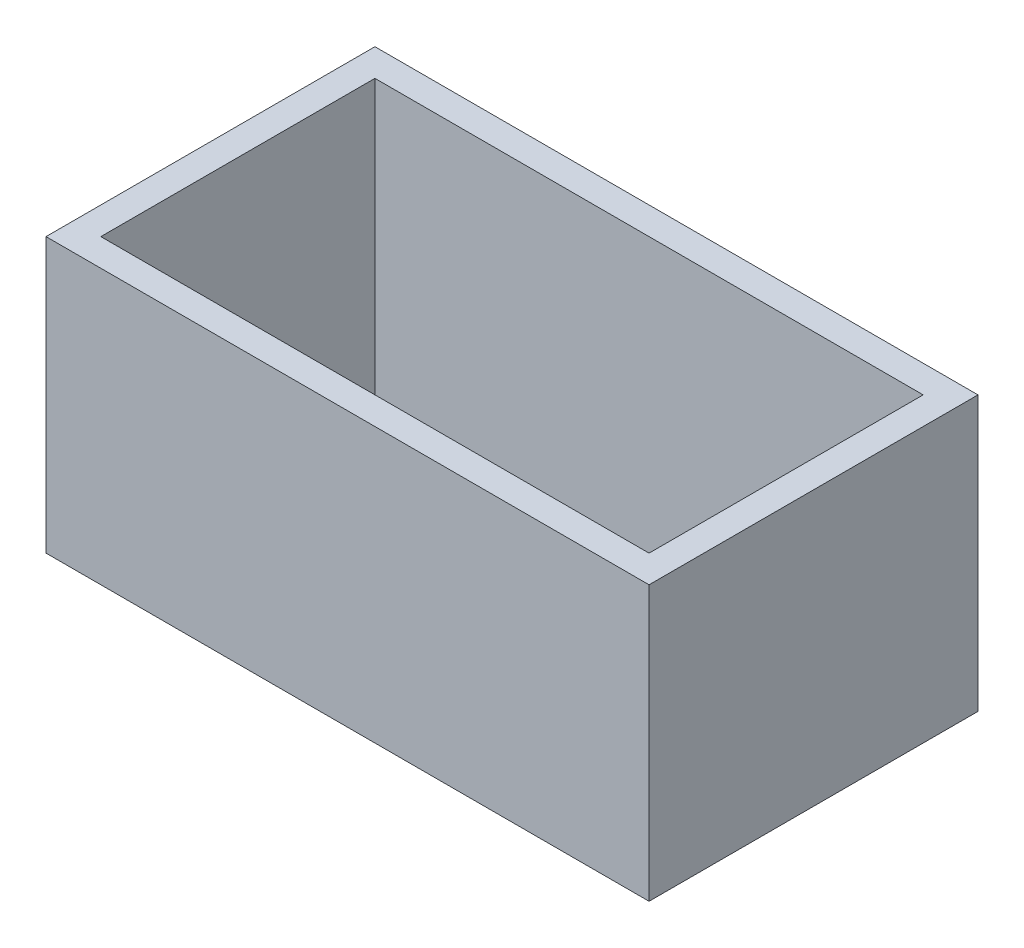
from build123d import *

# Parameters (mm, degrees)
SKETCH1_W           = 33
SKETCH1_H           = 18
SKETCH1_W_2         = 30
SKETCH1_H_2         = 15
BOSS_EXTRUDE1_DEPTH = 15


with BuildPart() as part:
    # Sketch1 → Boss-Extrude1 (new body)
    with BuildSketch(Plane(origin=(0, 0, 0), x_dir=(1, 0, 0), z_dir=(0, 1, 0))):
        Rectangle(SKETCH1_W, SKETCH1_H)
        Rectangle(SKETCH1_W_2, SKETCH1_H_2, mode=Mode.SUBTRACT)
    extrude(amount=BOSS_EXTRUDE1_DEPTH)


solid = part.part
